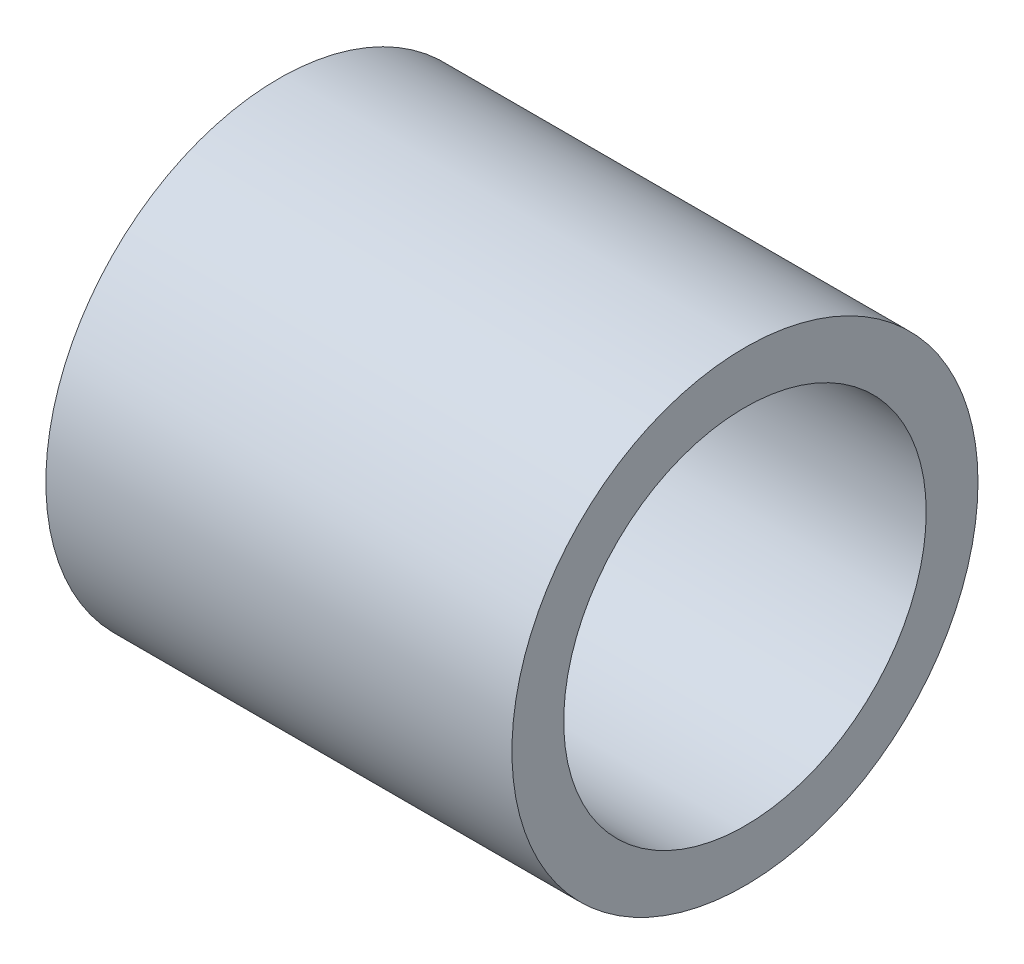
from build123d import *

# Parameters (mm, degrees)
SKETCH_1_R      = 9
SKETCH_1_R_2    = 7
EXTRUDE_1_DEPTH = 18


with BuildPart() as part:
    # 草图1 → 凸台-拉伸1 (new body)
    with BuildSketch(Plane(origin=(0, 0, 0), x_dir=(0, 0, -1), z_dir=(1, 0, 0))):
        Circle(SKETCH_1_R)
        Circle(SKETCH_1_R_2, mode=Mode.SUBTRACT)
    extrude(amount=-EXTRUDE_1_DEPTH)


solid = part.part
